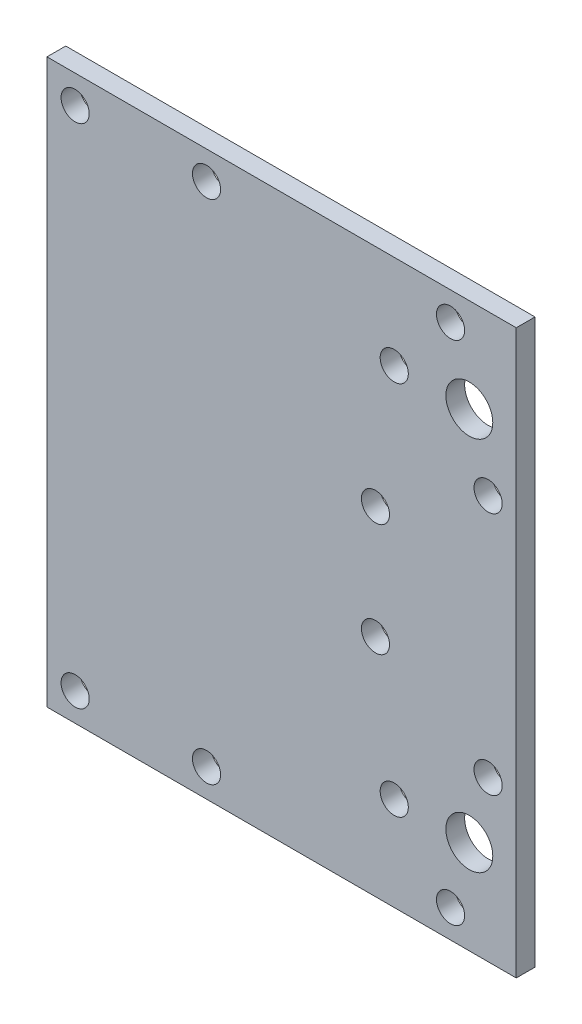
from build123d import *

# Parameters (mm, degrees)
SKETCH1_W           = 50
SKETCH1_H           = 60
SKETCH1_R           = 1.5
SKETCH1_R_2         = 2.5
BOSS_EXTRUDE1_DEPTH = 2


with BuildPart() as part:
    # Sketch1 → Boss-Extrude1 (new body)
    with BuildSketch(Plane.XY):
        with Locations((25, 30)):
            Rectangle(SKETCH1_W, SKETCH1_H)
        with Locations((3, 57)):
            Circle(SKETCH1_R, mode=Mode.SUBTRACT)
        with Locations((17, 57)):
            Circle(SKETCH1_R, mode=Mode.SUBTRACT)
        with Locations((17, 3)):
            Circle(SKETCH1_R, mode=Mode.SUBTRACT)
        with Locations((3, 3)):
            Circle(SKETCH1_R, mode=Mode.SUBTRACT)
        with Locations((47, 17)):
            Circle(SKETCH1_R, mode=Mode.SUBTRACT)
        with Locations((43, 3)):
            Circle(SKETCH1_R, mode=Mode.SUBTRACT)
        with Locations((47, 43)):
            Circle(SKETCH1_R, mode=Mode.SUBTRACT)
        with Locations((43, 57)):
            Circle(SKETCH1_R, mode=Mode.SUBTRACT)
        with Locations((35, 24)):
            Circle(SKETCH1_R, mode=Mode.SUBTRACT)
        with Locations((35, 36)):
            Circle(SKETCH1_R, mode=Mode.SUBTRACT)
        with Locations((37, 50)):
            Circle(SKETCH1_R, mode=Mode.SUBTRACT)
        with Locations((37, 10)):
            Circle(SKETCH1_R, mode=Mode.SUBTRACT)
        with Locations((45, 50)):
            Circle(SKETCH1_R_2, mode=Mode.SUBTRACT)
        with Locations((45, 10)):
            Circle(SKETCH1_R_2, mode=Mode.SUBTRACT)
    extrude(amount=BOSS_EXTRUDE1_DEPTH)


solid = part.part
